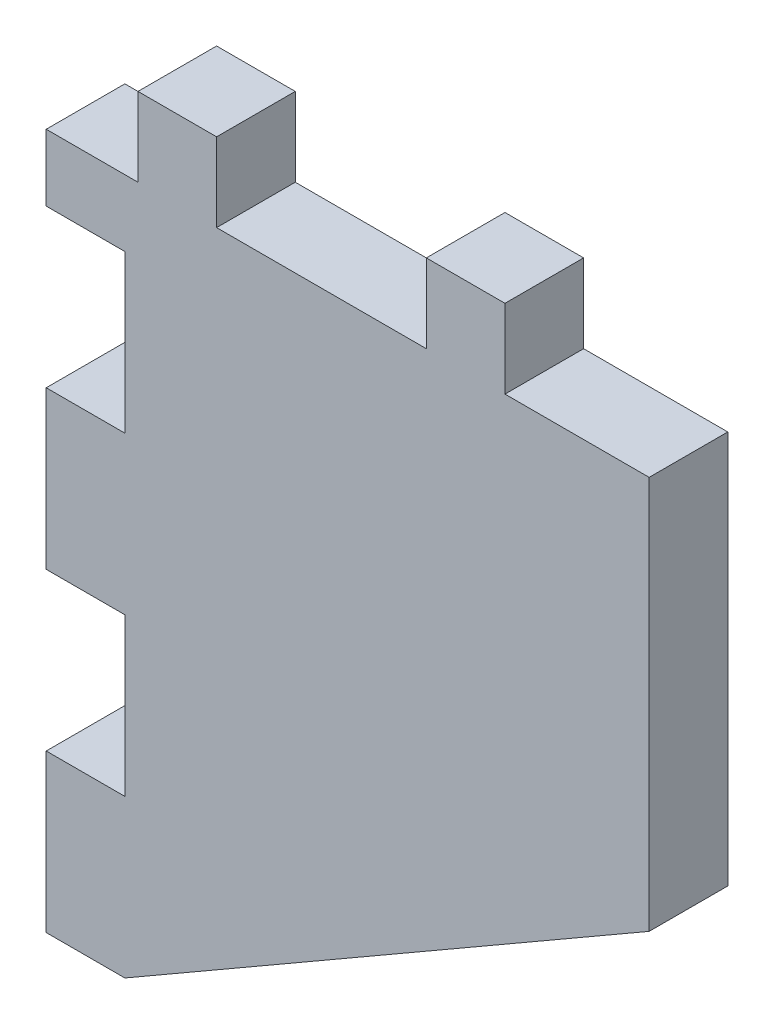
from build123d import *

# Parameters (mm, degrees)
BOSS_EXTRUDE1_DEPTH = 3
SKETCH2_W           = 3
SKETCH2_H           = 3
BOSS_EXTRUDE2_DEPTH = 3


with BuildPart() as part:
    # Sketch1 → Boss-Extrude1 (new body)
    with BuildSketch(Plane.XY):
        Polygon((-0.126642445, 14.929558907), (-0.126642445, -0.070441093), (-20.126642445, -11.610441093), (-23.126642445, -11.610441093), (-23.126642445, -5.610441093), (-20.126642445, -5.610441093), (-20.126642445, 0.389558907), (-23.126642445, 0.389558907), (-23.126642445, 6.389558907), (-20.126642445, 6.389558907), (-20.126642445, 12.389558907), (-23.126642445, 12.389558907), (-23.126642445, 14.929558907), (-14.126642445, 14.929558907), (-11.126642445, 14.929558907), (-3.126642445, 14.929558907), align=None)
    extrude(amount=BOSS_EXTRUDE1_DEPTH)

    # Sketch2 → Boss-Extrude2 (add)
    with BuildSketch(Plane.XY.offset(3)):
        with Locations((-7.126642445, 16.429558907)):
            Rectangle(SKETCH2_W, SKETCH2_H)
        with Locations((-18.126642445, 16.429558907)):
            Rectangle(SKETCH2_W, SKETCH2_H)
    extrude(amount=-BOSS_EXTRUDE2_DEPTH)


solid = part.part
